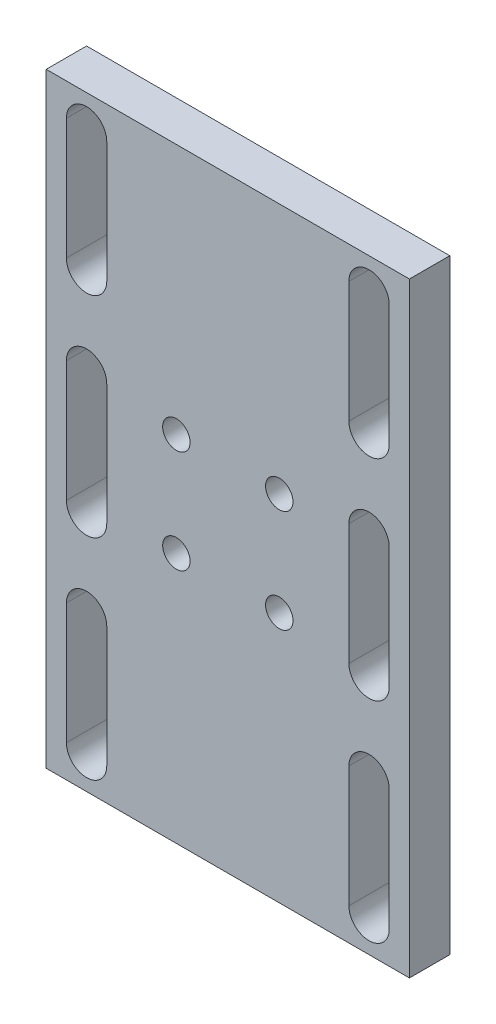
from build123d import *

# Parameters (mm, degrees)
SKETCH_2_W          = 90
SKETCH_2_H          = 150
EXTRUDE_1_DEPTH     = 10
SKETCH_3_W          = 57.822110836
SKETCH_3_H          = 142.808753936
EXTRUDE_2_DEPTH     = 10
CUT_EXTRUDE_1_REACH = 12
SKETCH_10_R         = 3.4


with BuildPart() as part:
    # 草圖2 → 填料-伸長1 (new body)
    with BuildSketch(Plane.XY):
        with Locations((0, 75)):
            Rectangle(SKETCH_2_W, SKETCH_2_H)
        with BuildLine():
            Line((40, 142), (40, 112))
            ThreePointArc((40, 112), (35, 107), (30, 112))
            Line((30, 112), (30, 142))
            ThreePointArc((30, 142), (35, 147), (40, 142))
        make_face(mode=Mode.SUBTRACT)
        with BuildLine():
            Line((27, 139.5), (27, 114.5))
            ThreePointArc((27, 114.5), (23.75, 111.25), (20.5, 114.5))
            Line((20.5, 114.5), (20.5, 139.5))
            ThreePointArc((20.5, 139.5), (23.75, 142.75), (27, 139.5))
        make_face(mode=Mode.SUBTRACT)
        with BuildLine():
            Line((-40, 142), (-40, 112))
            ThreePointArc((-40, 112), (-35, 107), (-30, 112))
            Line((-30, 112), (-30, 142))
            ThreePointArc((-30, 142), (-35, 147), (-40, 142))
        make_face(mode=Mode.SUBTRACT)
        with BuildLine():
            Line((-27, 139.5), (-27, 114.5))
            ThreePointArc((-27, 114.5), (-23.75, 111.25), (-20.5, 114.5))
            Line((-20.5, 114.5), (-20.5, 139.5))
            ThreePointArc((-20.5, 139.5), (-23.75, 142.75), (-27, 139.5))
        make_face(mode=Mode.SUBTRACT)
        with BuildLine():
            Line((40, 60), (40, 90))
            ThreePointArc((40, 90), (35, 95), (30, 90))
            Line((30, 90), (30, 60))
            ThreePointArc((30, 60), (35, 55), (40, 60))
        make_face(mode=Mode.SUBTRACT)
        with BuildLine():
            Line((27, 62.5), (27, 87.5))
            ThreePointArc((27, 87.5), (23.75, 90.75), (20.5, 87.5))
            Line((20.5, 87.5), (20.5, 62.5))
            ThreePointArc((20.5, 62.5), (23.75, 59.25), (27, 62.5))
        make_face(mode=Mode.SUBTRACT)
        with BuildLine():
            Line((-40, 60), (-40, 90))
            ThreePointArc((-40, 90), (-35, 95), (-30, 90))
            Line((-30, 90), (-30, 60))
            ThreePointArc((-30, 60), (-35, 55), (-40, 60))
        make_face(mode=Mode.SUBTRACT)
        with BuildLine():
            Line((-27, 62.5), (-27, 87.5))
            ThreePointArc((-27, 87.5), (-23.75, 90.75), (-20.5, 87.5))
            Line((-20.5, 87.5), (-20.5, 62.5))
            ThreePointArc((-20.5, 62.5), (-23.75, 59.25), (-27, 62.5))
        make_face(mode=Mode.SUBTRACT)
        with BuildLine():
            Line((-40, 8), (-40, 38))
            ThreePointArc((-40, 38), (-35, 43), (-30, 38))
            Line((-30, 38), (-30, 8))
            ThreePointArc((-30, 8), (-35, 3), (-40, 8))
        make_face(mode=Mode.SUBTRACT)
        with BuildLine():
            Line((-27, 10.5), (-27, 35.5))
            ThreePointArc((-27, 35.5), (-23.75, 38.75), (-20.5, 35.5))
            Line((-20.5, 35.5), (-20.5, 10.5))
            ThreePointArc((-20.5, 10.5), (-23.75, 7.25), (-27, 10.5))
        make_face(mode=Mode.SUBTRACT)
        with BuildLine():
            Line((40, 8), (40, 38))
            ThreePointArc((40, 38), (35, 43), (30, 38))
            Line((30, 38), (30, 8))
            ThreePointArc((30, 8), (35, 3), (40, 8))
        make_face(mode=Mode.SUBTRACT)
        with BuildLine():
            Line((27, 10.5), (27, 35.5))
            ThreePointArc((27, 35.5), (23.75, 38.75), (20.5, 35.5))
            Line((20.5, 35.5), (20.5, 10.5))
            ThreePointArc((20.5, 10.5), (23.75, 7.25), (27, 10.5))
        make_face(mode=Mode.SUBTRACT)
    extrude(amount=EXTRUDE_1_DEPTH)

    # 草圖3 → 填料-伸長2 (add)
    with BuildSketch(Plane.XY.offset(10)):
        with Locations((-0.145737049, 74.293544629)):
            Rectangle(SKETCH_3_W, SKETCH_3_H)
    extrude(amount=-EXTRUDE_2_DEPTH)

    # 草圖10 → 除料-伸長1 (cut, up to next)
    with BuildSketch(Plane.XY.offset(10), mode=Mode.PRIVATE) as cut_extrude_1_sk1:
        with Locations((12.75, 62.25)):
            Circle(SKETCH_10_R)
    cut_extrude_1_tool1 = extrude(cut_extrude_1_sk1.sketch, amount=-CUT_EXTRUDE_1_REACH, mode=Mode.PRIVATE) & part.part
    add(cut_extrude_1_tool1.solids().sort_by_distance((12.75, 62.25, 10))[0], mode=Mode.SUBTRACT)
    # 草圖10 → 除料-伸長1 (cut, up to next)
    with BuildSketch(Plane.XY.offset(10), mode=Mode.PRIVATE) as cut_extrude_1_sk2:
        with Locations((-12.75, 62.25)):
            Circle(SKETCH_10_R)
    cut_extrude_1_tool2 = extrude(cut_extrude_1_sk2.sketch, amount=-CUT_EXTRUDE_1_REACH, mode=Mode.PRIVATE) & part.part
    add(cut_extrude_1_tool2.solids().sort_by_distance((-12.75, 62.25, 10))[0], mode=Mode.SUBTRACT)
    # 草圖10 → 除料-伸長1 (cut, up to next)
    with BuildSketch(Plane.XY.offset(10), mode=Mode.PRIVATE) as cut_extrude_1_sk3:
        with Locations((12.75, 87.75)):
            Circle(SKETCH_10_R)
    cut_extrude_1_tool3 = extrude(cut_extrude_1_sk3.sketch, amount=-CUT_EXTRUDE_1_REACH, mode=Mode.PRIVATE) & part.part
    add(cut_extrude_1_tool3.solids().sort_by_distance((12.75, 87.75, 10))[0], mode=Mode.SUBTRACT)
    # 草圖10 → 除料-伸長1 (cut, up to next)
    with BuildSketch(Plane.XY.offset(10), mode=Mode.PRIVATE) as cut_extrude_1_sk4:
        with Locations((-12.75, 87.75)):
            Circle(SKETCH_10_R)
    cut_extrude_1_tool4 = extrude(cut_extrude_1_sk4.sketch, amount=-CUT_EXTRUDE_1_REACH, mode=Mode.PRIVATE) & part.part
    add(cut_extrude_1_tool4.solids().sort_by_distance((-12.75, 87.75, 10))[0], mode=Mode.SUBTRACT)


solid = part.part
